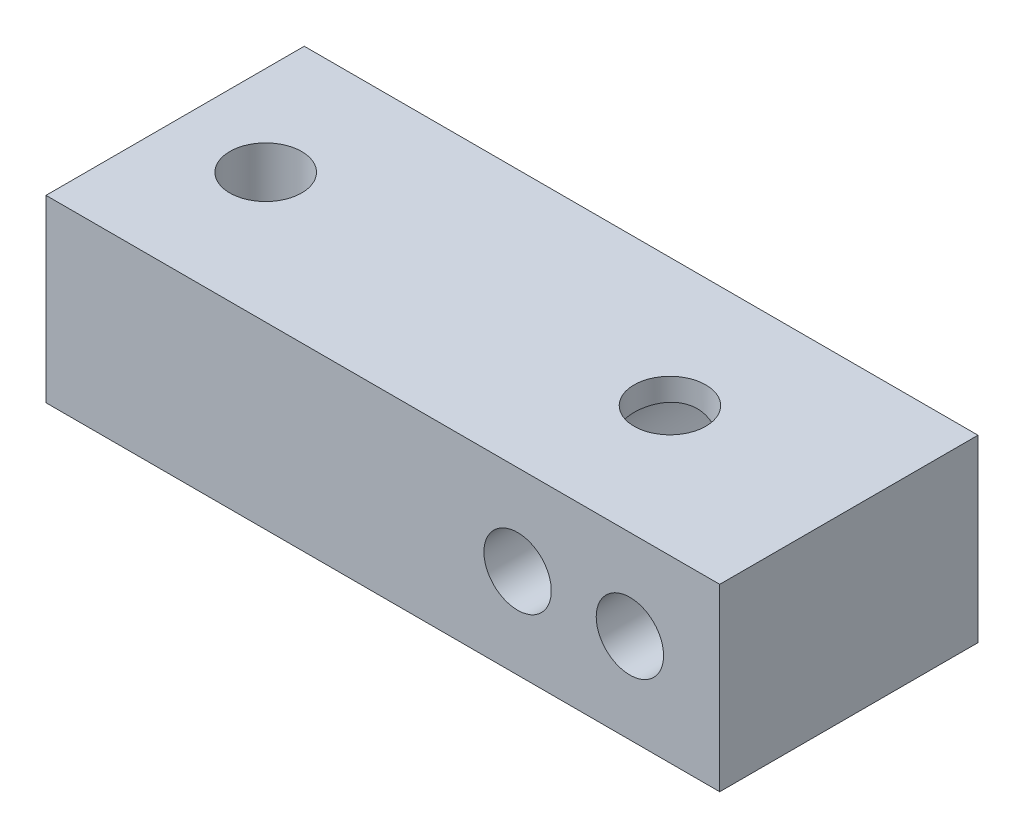
from build123d import *

# Parameters (mm, degrees)
SKETCH1_W           = 30
SKETCH1_H           = 11.5
BOSS_EXTRUDE1_DEPTH = 8
SKETCH2_R           = 1.5
CUT_EXTRUDE1_DEPTH  = 12.5
SKETCH3_R           = 1.598160281
SKETCH3_R_2         = 1.600993429
CUT_EXTRUDE2_DEPTH  = 10
CUT_EXTRUDE3_DEPTH  = 9


with BuildPart() as part:
    # Sketch1 → Boss-Extrude1 (new body)
    with BuildSketch(Plane(origin=(0, 0, 0), x_dir=(1, 0, 0), z_dir=(0, 1, 0))):
        with Locations((15, 5.75)):
            Rectangle(SKETCH1_W, SKETCH1_H)
    extrude(amount=BOSS_EXTRUDE1_DEPTH)

    # Sketch2 → Cut-Extrude1 (cut, through all)
    with BuildSketch(Plane(origin=(0, 0, -11.5), x_dir=(-1, 0, 0), z_dir=(0, 0, -1))):
        with Locations((-21, 4)):
            Circle(SKETCH2_R)
        with Locations((-26, 4)):
            Circle(SKETCH2_R)
    extrude(amount=-CUT_EXTRUDE1_DEPTH, mode=Mode.SUBTRACT)

    # Sketch3 → Cut-Extrude2 (cut)
    with BuildSketch(Plane.XZ):
        with Locations((21.998596175, -5.784390941)):
            Circle(SKETCH3_R)
        with Locations((4.000477604, -5.782705683)):
            Circle(SKETCH3_R_2)
    extrude(amount=-CUT_EXTRUDE2_DEPTH, mode=Mode.SUBTRACT)

    # Sketch4 → Cut-Extrude3 (cut)
    with BuildSketch(Plane(origin=(0, 0, -11.5), x_dir=(-1, 0, 0), z_dir=(0, 0, -1))):
        with BuildLine():
            ThreePointArc((-23.5, 5.658312395), (-29, 4), (-23.5, 2.341687605))
            ThreePointArc((-23.5, 2.341687605), (-18, 4), (-23.5, 5.658312395))
        make_face()
    extrude(amount=-CUT_EXTRUDE3_DEPTH, mode=Mode.SUBTRACT)


solid = part.part
